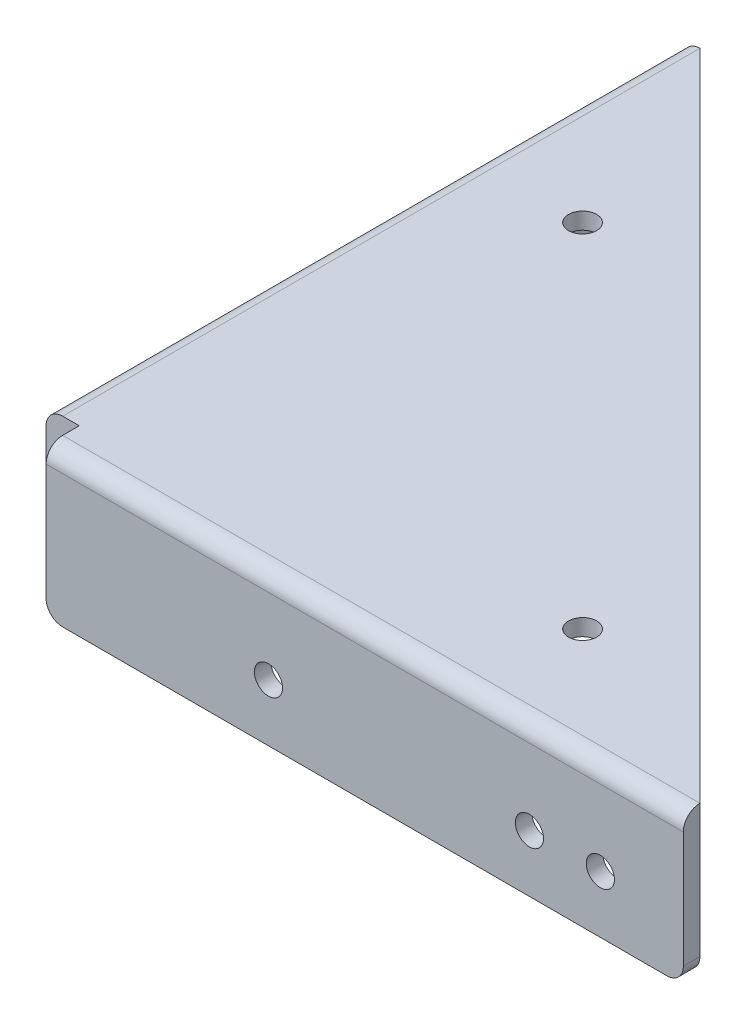
from build123d import *

# Parameters (mm, degrees)
BOSS_EXTRUDE3_DEPTH       = 22.86
BOSS_EXTRUDE4_DEPTH       = 2.54
FILLET1_R                 = 2.54
SKETCH4_W                 = 8.004359919
SKETCH4_H                 = 7.259840527
CUT_EXTRUDE1_DEPTH        = 32.004
CUT_EXTRUDE1_DEPTH_BACK   = 2.54
F_8_CLEARANCE_HOLE1_D     = 4.3053
F_8_CLEARANCE_HOLE1_DEPTH = 74.422
F_8_CLEARANCE_HOLE1_TIP   = 1.293442612
F_8_CLEARANCE_HOLE2_D     = 4.3053
F_8_CLEARANCE_HOLE2_DEPTH = 74.422
F_8_CLEARANCE_HOLE2_TIP   = 1.293442612
F_8_CLEARANCE_HOLE3_D     = 4.3053
F_8_CLEARANCE_HOLE3_DEPTH = 74.422
F_8_CLEARANCE_HOLE3_TIP   = 1.293442612
FILLET2_R                 = 2.54
SKETCH11_R                = 2.159
CUT_EXTRUDE2_DEPTH        = 7.62
SKETCH12_R                = 2.159
CUT_EXTRUDE3_DEPTH        = 7.62


with BuildPart() as part:
    # Sketch1 → Boss-Extrude3 (new body)
    with BuildSketch(Plane(origin=(0, 0, 0), x_dir=(1, 0, 0), z_dir=(0, 1, 0))):
        Polygon((102.616, 2.54), (102.616, 0), (0, 0), (0, 102.616), (2.54, 102.616), (2.54, 2.54), align=None)
    extrude(amount=BOSS_EXTRUDE3_DEPTH)

    # Sketch3 → Boss-Extrude4 (add)
    with BuildSketch(Plane(origin=(0, 22.86, 0), x_dir=(1, 0, 0), z_dir=(0, 1, 0))):
        Polygon((2.54, 102.616), (102.616, 2.54), (2.54, 2.54), align=None)
    extrude(amount=-BOSS_EXTRUDE4_DEPTH)

    # Fillet1
    fillet1_edges = [part.edges().sort_by_distance(p)[0] for p in [
        (0, 22.86, -51.308),
        (51.308, 22.86, 0),
        (2.54, 10.16, -2.54),
        (52.578, 20.32, -2.54),
        (2.54, 20.32, -52.578),
    ]]
    fillet(fillet1_edges, radius=FILLET1_R)

    # Sketch4 → Cut-Extrude1 (cut, two sides)
    with BuildSketch(Plane.XZ.offset(-20.32)) as cut_extrude1_sk:
        with Locations((1.077820041, -1.450079736)):
            Rectangle(SKETCH4_W, SKETCH4_H)
    extrude(amount=CUT_EXTRUDE1_DEPTH, mode=Mode.SUBTRACT)
    extrude(cut_extrude1_sk.sketch, amount=-CUT_EXTRUDE1_DEPTH_BACK, mode=Mode.SUBTRACT)

    # #8 Clearance Hole1
    with Locations(Plane(origin=(2.54, 0, 0), x_dir=(0, 0, -1), z_dir=(1, 0, 0))):
        with Locations((39.116, 8.73125), (89.916, 8.73125)):
            Hole(F_8_CLEARANCE_HOLE1_D / 2, depth=F_8_CLEARANCE_HOLE1_DEPTH)
            with Locations((0, 0, -(F_8_CLEARANCE_HOLE1_DEPTH + F_8_CLEARANCE_HOLE1_TIP / 2))):  # 118° drill point
                Cone(0, F_8_CLEARANCE_HOLE1_D / 2, F_8_CLEARANCE_HOLE1_TIP, mode=Mode.SUBTRACT)

    # #8 Clearance Hole2
    with Locations(Plane.XY):
        with Locations((89.916, 8.73125), (39.116, 8.73125)):
            Hole(F_8_CLEARANCE_HOLE2_D / 2, depth=F_8_CLEARANCE_HOLE2_DEPTH)
            with Locations((0, 0, -(F_8_CLEARANCE_HOLE2_DEPTH + F_8_CLEARANCE_HOLE2_TIP / 2))):  # 118° drill point
                Cone(0, F_8_CLEARANCE_HOLE2_D / 2, F_8_CLEARANCE_HOLE2_TIP, mode=Mode.SUBTRACT)

    # #8 Clearance Hole3
    with Locations(Plane(origin=(0, 20.32, 0), x_dir=(-1, 0, 0), z_dir=(0, -1, 0))):
        with Locations((-16.656975516, 70.538512242), (-70.538512242, 16.656975516)):
            Hole(F_8_CLEARANCE_HOLE3_D / 2, depth=F_8_CLEARANCE_HOLE3_DEPTH)
            with Locations((0, 0, -(F_8_CLEARANCE_HOLE3_DEPTH + F_8_CLEARANCE_HOLE3_TIP / 2))):  # 118° drill point
                Cone(0, F_8_CLEARANCE_HOLE3_D / 2, F_8_CLEARANCE_HOLE3_TIP, mode=Mode.SUBTRACT)

    # Fillet2
    fillet2_edges = [part.edges().sort_by_distance(p)[0] for p in [
        (1.27, 0, -5.08),
        (5.08, 0, -1.27),
        (1.27, 0, -102.616),
        (102.616, 0, -1.27),
    ]]
    fillet(fillet2_edges, radius=FILLET2_R)

    # Sketch11 → Cut-Extrude2 (cut)
    with BuildSketch(Plane(origin=(2.54, 0, 0), x_dir=(0, 0, -1), z_dir=(1, 0, 0))):
        with Locations((79.0575, 8.73125)):
            Circle(SKETCH11_R)
    extrude(amount=-CUT_EXTRUDE2_DEPTH, mode=Mode.SUBTRACT)

    # Sketch12 → Cut-Extrude3 (cut)
    with BuildSketch(Plane.XY):
        with Locations((79.0575, 8.73125)):
            Circle(SKETCH12_R)
    extrude(amount=-CUT_EXTRUDE3_DEPTH, mode=Mode.SUBTRACT)


solid = part.part
